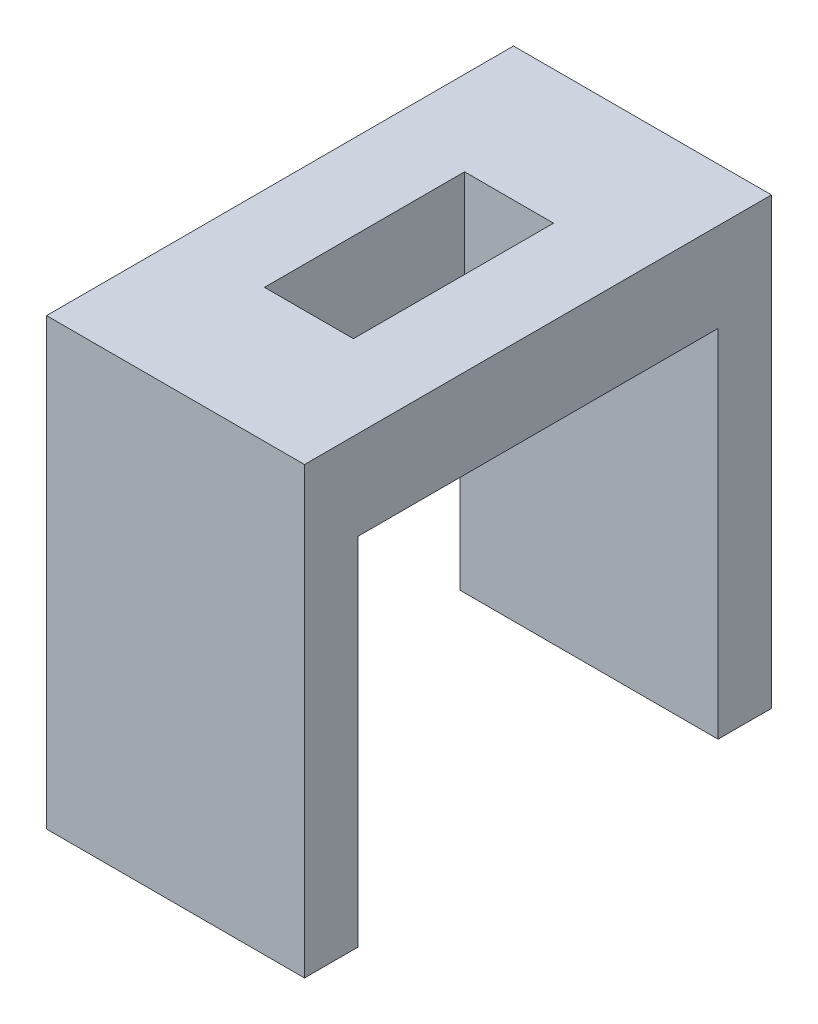
from build123d import *

# Parameters (mm, degrees)
CROQUIS1_W              = 5.8
CROQUIS1_H              = 10.5
CROQUIS1_W_2            = 2
CROQUIS1_H_2            = 4.5
SALIENTE_EXTRUIR1_DEPTH = 2
CROQUIS2_W              = 5.8
CROQUIS2_H              = 1.2
SALIENTE_EXTRUIR2_DEPTH = 8


with BuildPart() as part:
    # Croquis1 → Saliente-Extruir1 (new body)
    with BuildSketch(Plane(origin=(0, 0, 0), x_dir=(1, 0, 0), z_dir=(0, 1, 0))):
        with Locations((2.9, 5.25)):
            Rectangle(CROQUIS1_W, CROQUIS1_H)
        with Locations((2.9, 5.25)):
            Rectangle(CROQUIS1_W_2, CROQUIS1_H_2, mode=Mode.SUBTRACT)
    extrude(amount=SALIENTE_EXTRUIR1_DEPTH)

    # Croquis2 → Saliente-Extruir2 (add)
    with BuildSketch(Plane(origin=(0, 0, 0), x_dir=(-1, 0, 0), z_dir=(0, -1, 0))):
        with Locations((-2.9, 9.9)):
            Rectangle(CROQUIS2_W, CROQUIS2_H)
        with Locations((-2.9, 0.6)):
            Rectangle(CROQUIS2_W, CROQUIS2_H)
    extrude(amount=SALIENTE_EXTRUIR2_DEPTH)


solid = part.part
